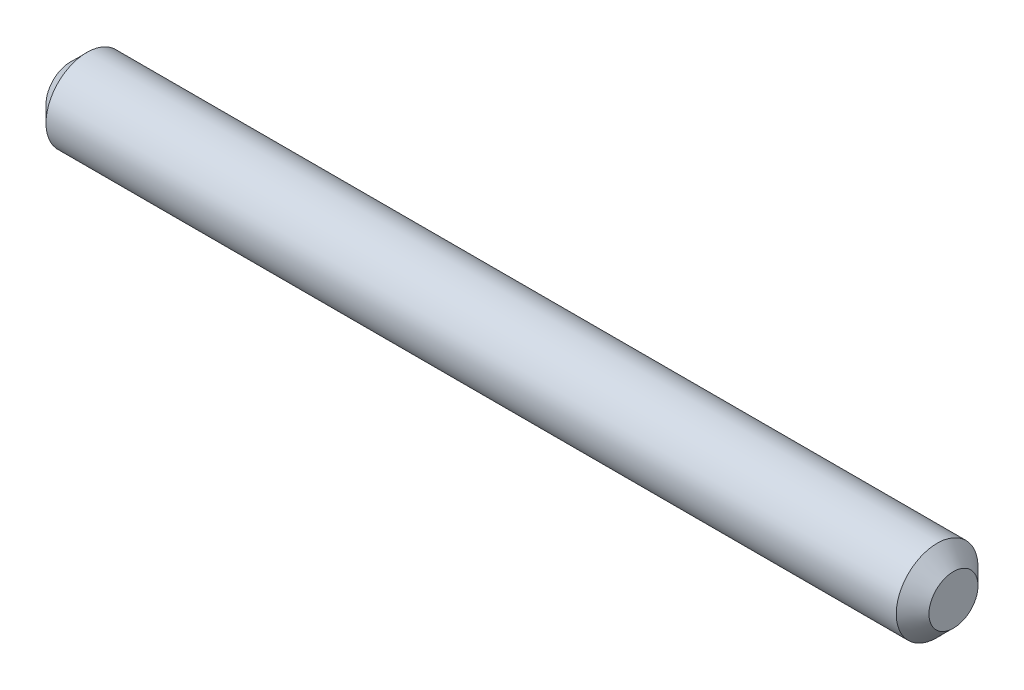
from build123d import *

# Parameters (mm, degrees)
SKETCH1_W     = 54
SKETCH1_H     = 2.5
CHAMFER1_SIZE = 1


with BuildPart() as part:
    # Sketch1 → Revolve1 (revolve)
    with BuildSketch(Plane.XY):
        with Locations((-2.916897507, 1.25)):
            Rectangle(SKETCH1_W, SKETCH1_H)
    revolve(axis=Axis((-29.916897507, 0, 0), (1, 0, 0)))

    # Chamfer1
    chamfer1_edges = [part.edges().sort_by_distance(p)[0] for p in [
        (24.083102493, -2.5, 0),
        (-29.916897507, -2.5, 0),
    ]]
    chamfer(chamfer1_edges, length=CHAMFER1_SIZE)


solid = part.part
